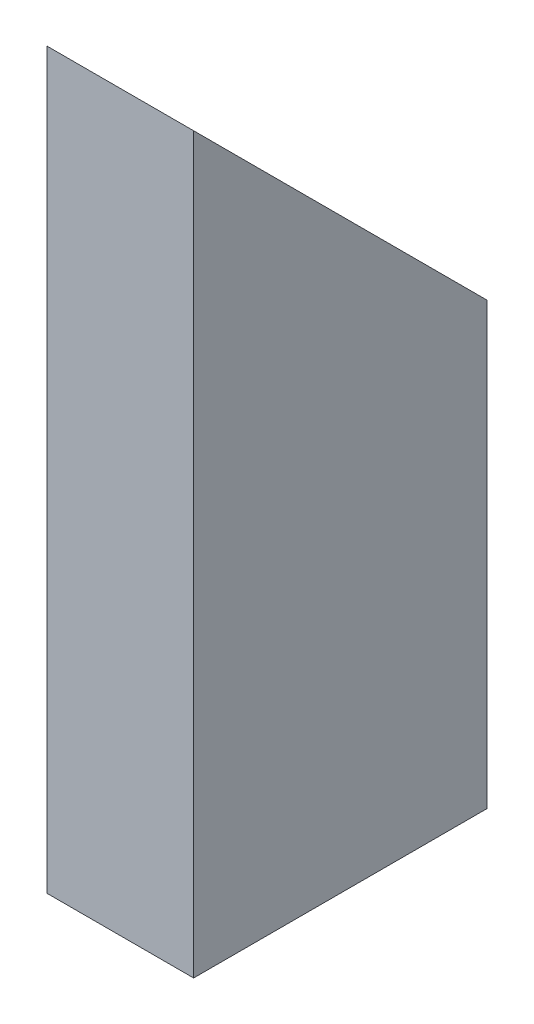
from build123d import *

# Parameters (mm, degrees)
SKETCH1_W           = 25.4
SKETCH1_H           = 50.8
SKETCH1_W_2         = 19.05
SKETCH1_H_2         = 44.45
BOSS_EXTRUDE1_DEPTH = 127
CUT_EXTRUDE1_DEPTH  = 127


with BuildPart() as part:
    # Sketch1 → Boss-Extrude1 (new body)
    with BuildSketch(Plane(origin=(0, 0, 0), x_dir=(1, 0, 0), z_dir=(0, 1, 0))):
        with Locations((12.7, 25.4)):
            Rectangle(SKETCH1_W, SKETCH1_H)
        with Locations((12.7, 25.4)):
            Rectangle(SKETCH1_W_2, SKETCH1_H_2, mode=Mode.SUBTRACT)
    extrude(amount=BOSS_EXTRUDE1_DEPTH)

    # Sketch2 → Cut-Extrude1 (cut)
    with BuildSketch(Plane(origin=(25.4, 0, 0), x_dir=(0, 0, -1), z_dir=(1, 0, 0))):
        Polygon((0, 127), (50.8, 76.2), (50.8, 127), align=None)
    extrude(amount=-CUT_EXTRUDE1_DEPTH, mode=Mode.SUBTRACT)


solid = part.part
